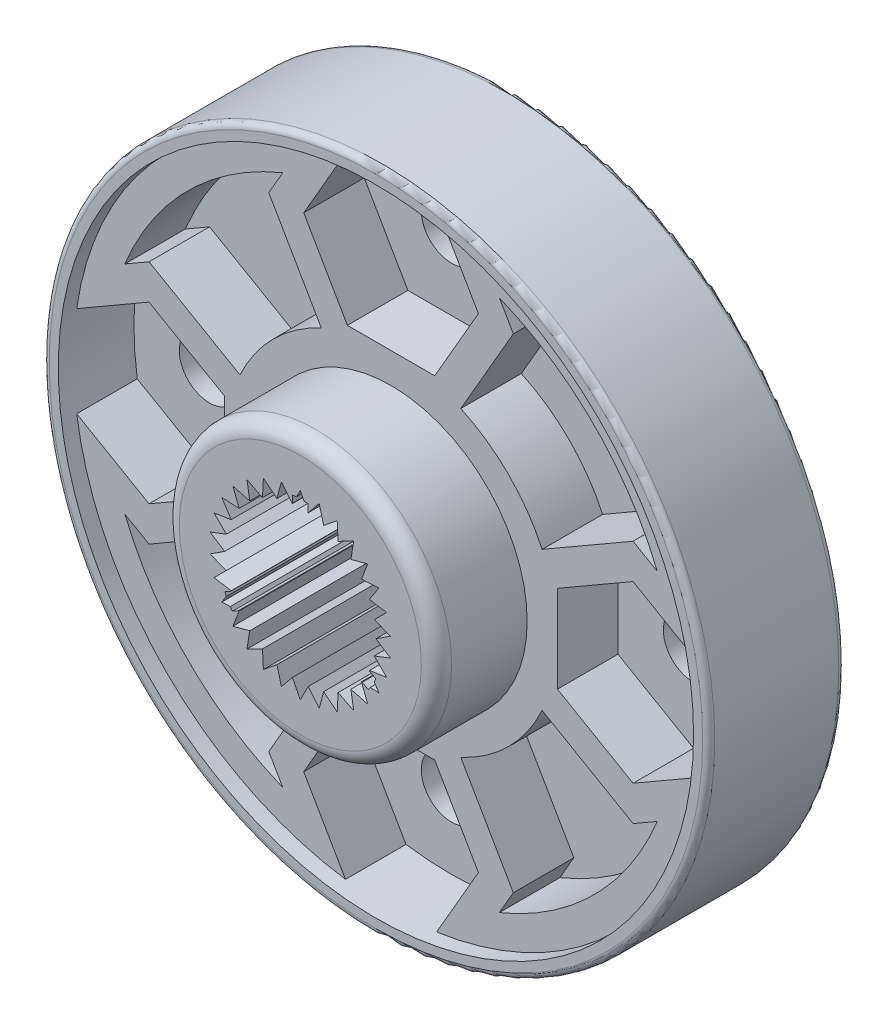
from build123d import *

# Parameters (mm, degrees)
SKETCH_1_R           = 11
EXTRUDE_1_DEPTH      = 4.5
SKETCH_2_R           = 4.5
EXTRUDE_2_DEPTH      = 2.5
SKETCH_3_R           = 3.75
EXTRUDE_3_DEPTH      = 0.5
SKETCH_4_R           = 2.75
CUT_EXTRUDE_1_DEPTH  = 2
CUT_EXTRUDE_2_DEPTH  = 5
SKETCH_6_R           = 1
CUT_EXTRUDE_3_DEPTH  = 8
SKETCH_7_R           = 0.75
CUT_EXTRUDE_4_DEPTH  = 0.2
SKETCH_8_R           = 1
CUT_EXTRUDE_5_DEPTH  = 0.2
EXTRUDE_4_DEPTH      = 0.1
EXTRUDE_5_DEPTH      = 0.1
EXTRUDE_6_DEPTH      = 0.1
SKETCH_12_R          = 10.5
SKETCH_12_R_2        = 4.5
CUT_EXTRUDE_7_DEPTH  = 0.5
SKETCH_13_R          = 1
CUT_EXTRUDE_9_DEPTH  = 2
FILLET_1_R           = 0.5
CUT_EXTRUDE_10_DEPTH = 6.5
FILLET_2_R           = 0.2


with BuildPart() as part:
    # 草图1 → 拉伸1 (new body)
    with BuildSketch(Plane.XY):
        Circle(SKETCH_1_R)
    extrude(amount=EXTRUDE_1_DEPTH)

    # 草图2 → 拉伸2 (add)
    with BuildSketch(Plane.XY.offset(4.5)):
        Circle(SKETCH_2_R)
    extrude(amount=EXTRUDE_2_DEPTH)

    # 草图3 → 拉伸3 (add)
    with BuildSketch(Plane(origin=(0, 0, 0), x_dir=(-1, 0, 0), z_dir=(0, 0, -1))):
        Circle(SKETCH_3_R)
    extrude(amount=EXTRUDE_3_DEPTH)

    # 草图4 → 切除-拉伸1 (cut)
    with BuildSketch(Plane(origin=(0, 0, -0.5), x_dir=(-1, 0, 0), z_dir=(0, 0, -1))):
        Circle(SKETCH_4_R)
    extrude(amount=-CUT_EXTRUDE_1_DEPTH, mode=Mode.SUBTRACT)

    # 草图5 → 切除-拉伸2 (cut)
    with BuildSketch(Plane.XY.offset(7)):
        Polygon((0, 3), (-0.261321158, 2.486304738), (-0.623735072, 2.934442802), (-0.772542486, 2.377641291), (-1.220209929, 2.740636373), (-1.25, 2.165063509), (-1.763355757, 2.427050983), (-1.672826516, 1.857862064), (-2.229434476, 2.007391819), (-2.022542486, 1.469463131), (-2.598076211, 1.5), (-2.283863644, 1.016841608), (-2.853169549, 0.927050983), (-2.445369002, 0.519779227), (-2.983565686, 0.31358539), (-2.5, 0), (-2.983565686, -0.31358539), (-2.445369002, -0.519779227), (-2.853169549, -0.927050983), (-2.283863644, -1.016841608), (-2.598076211, -1.5), (-2.022542486, -1.469463131), (-2.229434476, -2.007391819), (-1.672826516, -1.857862064), (-1.763355757, -2.427050983), (-1.25, -2.165063509), (-1.220209929, -2.740636373), (-0.772542486, -2.377641291), (-0.623735072, -2.934442802), (-0.261321158, -2.486304738), (0, -3), (0.261321158, -2.486304738), (0.623735072, -2.934442802), (0.772542486, -2.377641291), (1.220209929, -2.740636373), (1.25, -2.165063509), (1.763355757, -2.427050983), (1.672826516, -1.857862064), (2.229434476, -2.007391819), (2.022542486, -1.469463131), (2.598076211, -1.5), (2.283863644, -1.016841608), (2.853169549, -0.927050983), (2.445369002, -0.519779227), (2.983565686, -0.31358539), (2.5, 0), (2.983565686, 0.31358539), (2.445369002, 0.519779227), (2.853169549, 0.927050983), (2.283863644, 1.016841608), (2.598076211, 1.5), (2.022542486, 1.469463131), (2.229434476, 2.007391819), (1.672826516, 1.857862064), (1.763355757, 2.427050983), (1.25, 2.165063509), (1.220209929, 2.740636373), (0.772542486, 2.377641291), (0.623735072, 2.934442802), (0.261321158, 2.486304738), align=None)
    extrude(amount=-CUT_EXTRUDE_2_DEPTH, mode=Mode.SUBTRACT)

    # 草图6 → 切除-拉伸3 (cut, through all)
    with BuildSketch(Plane(origin=(0, 0, 0), x_dir=(-1, 0, 0), z_dir=(0, 0, -1))):
        with Locations((0, 8)):
            Circle(SKETCH_6_R)
        with Locations((8, 0)):
            Circle(SKETCH_6_R)
        with Locations((0, -8)):
            Circle(SKETCH_6_R)
        with Locations((-8, 0)):
            Circle(SKETCH_6_R)
    extrude(amount=-CUT_EXTRUDE_3_DEPTH, mode=Mode.SUBTRACT)

    # 草图7 → 切除-拉伸4 (cut)
    with BuildSketch(Plane(origin=(0, 0, 0), x_dir=(-1, 0, 0), z_dir=(0, 0, -1))):
        with Locations((0, 5.196152423)):
            Circle(SKETCH_7_R)
        with Locations((4.5, 2.598076211)):
            Circle(SKETCH_7_R)
        with Locations((4.5, -2.598076211)):
            Circle(SKETCH_7_R)
        with Locations((0, -5.196152423)):
            Circle(SKETCH_7_R)
        with Locations((-4.5, -2.598076211)):
            Circle(SKETCH_7_R)
        with Locations((-4.5, 2.598076211)):
            Circle(SKETCH_7_R)
    extrude(amount=-CUT_EXTRUDE_4_DEPTH, mode=Mode.SUBTRACT)

    # 草图8 → 切除-拉伸5 (cut)
    with BuildSketch(Plane(origin=(0, 0, 0), x_dir=(-1, 0, 0), z_dir=(0, 0, -1))):
        with Locations((0, 5.196152423)):
            Circle(SKETCH_8_R)
        with Locations((-4.5, -2.598076211)):
            Circle(SKETCH_8_R)
        with Locations((4.5, -2.598076211)):
            Circle(SKETCH_8_R)
    extrude(amount=-CUT_EXTRUDE_5_DEPTH, mode=Mode.SUBTRACT)

    # 草图9 → 拉伸4 (add)
    with BuildSketch(Plane(origin=(0, 0, 0.2), x_dir=(-1, 0, 0), z_dir=(0, 0, -1))):
        with BuildLine():
            Line((0.089651905, 6.056310688), (0.089651905, 4.73697475))
            add(Edge.make_bspline(
                [(0.089651905, 4.73697475), (0.090054867, 4.726061292), (0.090821432, 4.705300356), (0.099215446, 4.676319591), (0.112611431, 4.651356313), (0.13217496, 4.631390679), (0.156552186, 4.616383854), (0.185168592, 4.605627027), (0.217951485, 4.599206542), (0.241205917, 4.598399935), (0.253388884, 4.597977354)],
                knots=[0, 0, 0, 0, 3.2656e-05, 6.2122e-05, 8.9661e-05, 0.000116826, 0.000144913, 0.000174899, 0.000208095, 0.000244625, 0.000244625, 0.000244625, 0.000244625], degree=3))
            Line((0.253388884, 4.597977354), (0.339651905, 4.597977354))
            Line((0.339651905, 4.597977354), (0.339651905, 4.535477354))
            Line((0.339651905, 4.535477354), (-0.306181428, 4.535477354))
            Line((-0.306181428, 4.535477354), (-0.306181428, 4.597977354))
            Line((-0.306181428, 4.597977354), (-0.225777783, 4.597977354))
            add(Edge.make_bspline(
                [(-0.225777783, 4.597977354), (-0.211865389, 4.598406268), (-0.186051926, 4.599202087), (-0.1501756, 4.605109615), (-0.120288816, 4.615635163), (-0.096165753, 4.630911614), (-0.077851254, 4.650963182), (-0.06509053, 4.675284495), (-0.057494897, 4.703869515), (-0.056636456, 4.72422955), (-0.056181428, 4.735021625)],
                knots=[0, 0, 0, 0, 4.1729e-05, 7.7425e-05, 0.000108629, 0.000136168, 0.000162204, 0.000189145, 0.00021781, 0.000250141, 0.000250141, 0.000250141, 0.000250141], degree=3))
            Line((-0.056181428, 4.735021625), (-0.056181428, 5.770828917))
            add(Edge.make_bspline(
                [(-0.056181428, 5.770828917), (-0.056380806, 5.776286462), (-0.056766367, 5.78684037), (-0.061232198, 5.801922344), (-0.068381533, 5.815381019), (-0.078422418, 5.826992213), (-0.091012726, 5.836710591), (-0.106732564, 5.84355908), (-0.125232107, 5.847314594), (-0.138412095, 5.847748273), (-0.145374137, 5.847977354)],
                knots=[0, 0, 0, 0, 1.6328e-05, 3.1575e-05, 4.6722e-05, 6.1728e-05, 7.7288e-05, 9.4045e-05, 0.000112688, 0.000133562, 0.000133562, 0.000133562, 0.000133562], degree=3))
            Line((-0.145374137, 5.847977354), (-0.306181428, 5.847977354))
            Line((-0.306181428, 5.847977354), (-0.306181428, 5.910477354))
            Line((-0.306181428, 5.910477354), (-0.225126741, 5.910477354))
            add(Edge.make_bspline(
                [(-0.225126741, 5.910477354), (-0.207956505, 5.910865388), (-0.175202241, 5.911605607), (-0.128556059, 5.918495829), (-0.086854939, 5.929613877), (-0.049979918, 5.94579303), (-0.017577184, 5.9665729), (0.010725271, 5.99188936), (0.03495573, 6.02192616), (0.047249188, 6.044697076), (0.053519092, 6.056310688)],
                knots=[0, 0, 0, 0, 5.1483e-05, 9.8209e-05, 0.000141092, 0.000180589, 0.000218513, 0.000256089, 0.000294065, 0.000333594, 0.000333594, 0.000333594, 0.000333594], degree=3))
            Line((0.053519092, 6.056310688), (0.089651905, 6.056310688))
        make_face()
    extrude(amount=EXTRUDE_4_DEPTH)

    # 草图10 → 拉伸5 (add)
    with BuildSketch(Plane(origin=(0, 0, 0.2), x_dir=(-1, 0, 0), z_dir=(0, 0, -1))):
        with BuildLine():
            add(Edge.make_bspline(
                [(-4.923502604, -2.534274128), (-4.934438682, -2.54142001), (-4.955623116, -2.555262402), (-4.985188438, -2.577541336), (-5.011476174, -2.600438324), (-5.034386196, -2.624102537), (-5.054551495, -2.647963004), (-5.071504649, -2.672526123), (-5.084963819, -2.697944466), (-5.095468831, -2.72364453), (-5.102826259, -2.74993959), (-5.106408787, -2.776779833), (-5.10631326, -2.804013259), (-5.102981037, -2.831636465), (-5.096393948, -2.859672691), (-5.086556945, -2.888172234), (-5.073068652, -2.917044907), (-5.061810664, -2.935740273), (-5.055989583, -2.945406941)],
                knots=[0, 0, 0, 0, 3.9183e-05, 7.5902e-05, 0.000110965, 0.000143653, 0.00017462, 0.000204597, 0.000232994, 0.000260739, 0.000287748, 0.00031468, 0.000341698, 0.000369235, 0.000397977, 0.000427933, 0.000459536, 0.000493371, 0.000493371, 0.000493371, 0.000493371], degree=3))
            add(Edge.make_bspline(
                [(-5.055989583, -2.945406941), (-5.046458284, -2.959230981), (-5.027890491, -2.986161405), (-4.992903828, -3.019703109), (-4.954205817, -3.046703542), (-4.918424437, -3.062235248), (-4.888975583, -3.071119168), (-4.866897586, -3.075034354), (-4.845174123, -3.076277145), (-4.823957293, -3.075480516), (-4.803145293, -3.071652662), (-4.782649248, -3.065941006), (-4.76252748, -3.057370768), (-4.749918009, -3.04983479), (-4.743489583, -3.045992878)],
                knots=[0, 0, 0, 0, 5.0261e-05, 9.7913e-05, 0.000144503, 0.000191139, 0.000214212, 0.00023669, 0.000258213, 0.000279395, 0.000300213, 0.000321541, 0.000343127, 0.000365576, 0.000365576, 0.000365576, 0.000365576], degree=3))
            add(Edge.make_bspline(
                [(-4.743489583, -3.045992878), (-4.736283626, -3.040984911), (-4.722267198, -3.031243831), (-4.704288218, -3.013651985), (-4.691137931, -2.993321697), (-4.682143835, -2.971757183), (-4.67484291, -2.950513489), (-4.663744304, -2.932639535), (-4.651470767, -2.91721807), (-4.641145958, -2.909929378), (-4.636067708, -2.906344441)],
                knots=[0, 0, 0, 0, 2.6303e-05, 5.1162e-05, 7.4907e-05, 9.8374e-05, 0.000121163, 0.000142042, 0.000161215, 0.000179772, 0.000179772, 0.000179772, 0.000179772], degree=3))
            add(Edge.make_bspline(
                [(-4.636067708, -2.906344441), (-4.629880584, -2.90266612), (-4.618227256, -2.895738075), (-4.600153119, -2.889044397), (-4.583005407, -2.886252397), (-4.566665212, -2.887048246), (-4.551336831, -2.89224464), (-4.536852904, -2.900852239), (-4.524184985, -2.914140072), (-4.516888268, -2.924576111), (-4.513020833, -2.930107461)],
                knots=[0, 0, 0, 0, 2.1563e-05, 4.0614e-05, 5.7418e-05, 7.3399e-05, 8.9149e-05, 0.000105506, 0.00012346, 0.000143708, 0.000143708, 0.000143708, 0.000143708], degree=3))
            add(Edge.make_bspline(
                [(-4.513020833, -2.930107461), (-4.508913691, -2.937125984), (-4.501015104, -2.950623547), (-4.494520421, -2.972560199), (-4.492321165, -2.994269974), (-4.495275481, -3.016007298), (-4.504119473, -3.037348703), (-4.519145779, -3.058095292), (-4.54066524, -3.077742758), (-4.557878585, -3.089306101), (-4.567057292, -3.095472045)],
                knots=[0, 0, 0, 0, 2.4318e-05, 4.6768e-05, 6.8016e-05, 8.9377e-05, 0.000111864, 0.000136612, 0.000165629, 0.000198778, 0.000198778, 0.000198778, 0.000198778], degree=3))
            add(Edge.make_bspline(
                [(-4.567057292, -3.095472045), (-4.580036634, -3.103241135), (-4.605362781, -3.118400697), (-4.644955142, -3.135879651), (-4.684141672, -3.148946663), (-4.723342795, -3.156367591), (-4.762220025, -3.159444899), (-4.801096167, -3.157551866), (-4.839627282, -3.150155326), (-4.877503904, -3.138401383), (-4.913913093, -3.123052842), (-4.948595748, -3.105553198), (-4.980723318, -3.085547475), (-5.010989645, -3.064104083), (-5.038767581, -3.040228739), (-5.064122499, -3.014091835), (-5.087462554, -2.986099225), (-5.1009747, -2.965932019), (-5.107747396, -2.955823607)],
                knots=[0, 0, 0, 0, 4.5342e-05, 8.8475e-05, 0.000129548, 0.000169002, 0.00020785, 0.000246311, 0.000285384, 0.000325232, 0.000365071, 0.000403796, 0.000441649, 0.000478506, 0.000514979, 0.00055135, 0.000587652, 0.000624134, 0.000624134, 0.000624134, 0.000624134], degree=3))
            add(Edge.make_bspline(
                [(-5.107747396, -2.955823607), (-5.116474892, -2.941536596), (-5.133379472, -2.913863603), (-5.153637862, -2.871266437), (-5.170439256, -2.830256823), (-5.181709635, -2.789907598), (-5.189245184, -2.750829479), (-5.1914856, -2.712658245), (-5.189321381, -2.675687239), (-5.18233837, -2.639987105), (-5.17144576, -2.60586942), (-5.157747844, -2.573170822), (-5.141193472, -2.542058477), (-5.121102771, -2.512894253), (-5.097962867, -2.485657292), (-5.07198717, -2.459998938), (-5.042922393, -2.436078695), (-5.021619732, -2.421997903), (-5.010742187, -2.414807982)],
                knots=[0, 0, 0, 0, 5.019e-05, 9.7216e-05, 0.000141342, 0.000182971, 0.000222685, 0.000260514, 0.000297368, 0.000333502, 0.00036933, 0.000404637, 0.000439736, 0.000474859, 0.000510662, 0.0005468, 0.000584271, 0.000623367, 0.000623367, 0.000623367, 0.000623367], degree=3))
            add(Edge.make_bspline(
                [(-5.010742187, -2.414807982), (-4.995523968, -2.40586697), (-4.964773778, -2.387800609), (-4.914775923, -2.367321955), (-4.861777201, -2.351557983), (-4.805762047, -2.340757328), (-4.746507714, -2.335866148), (-4.684417769, -2.337623814), (-4.619683572, -2.346223471), (-4.576311745, -2.356480296), (-4.554036458, -2.361748086)],
                knots=[0, 0, 0, 0, 5.2896e-05, 0.000106882, 0.000161571, 0.000218582, 0.000277703, 0.000339573, 0.00040458, 0.000473218, 0.000473218, 0.000473218, 0.000473218], degree=3))
            add(Edge.make_bspline(
                [(-4.554036458, -2.361748086), (-4.526047464, -2.367851881), (-4.471609687, -2.379723584), (-4.392063103, -2.396596104), (-4.316972392, -2.412541141), (-4.246068169, -2.42574144), (-4.179921773, -2.438929245), (-4.117986253, -2.449442248), (-4.06048495, -2.458935808), (-4.007423022, -2.467084975), (-3.958816058, -2.473981797), (-3.914756948, -2.479526143), (-3.875134531, -2.483754492), (-3.84008646, -2.487043942), (-3.809480851, -2.489354396), (-3.783334668, -2.49076807), (-3.761683458, -2.491065035), (-3.748802198, -2.489873701), (-3.743164062, -2.489352253)],
                knots=[0, 0, 0, 0, 8.594e-05, 0.000167151, 0.000243952, 0.000316221, 0.00038351, 0.000446285, 0.00050467, 0.000558351, 0.000607333, 0.000651948, 0.000691563, 0.000726869, 0.000757553, 0.000783627, 0.000805437, 0.000822414, 0.000822414, 0.000822414, 0.000822414], degree=3))
            Line((-3.743164062, -2.489352253), (-4.015625, -2.056409545))
            add(Edge.make_bspline(
                [(-4.015625, -2.056409545), (-4.022878312, -2.046136926), (-4.037100032, -2.025995188), (-4.066152514, -2.00273789), (-4.099872125, -1.986475093), (-4.138263413, -1.977560621), (-4.180981408, -1.975621502), (-4.227535668, -1.98259356), (-4.278329551, -1.996381336), (-4.312338361, -2.010924097), (-4.330403646, -2.018649128)],
                knots=[0, 0, 0, 0, 3.7572e-05, 7.3668e-05, 0.000110211, 0.000149055, 0.000191093, 0.000237729, 0.00028969, 0.000348566, 0.000348566, 0.000348566, 0.000348566], degree=3))
            Line((-4.330403646, -2.018649128), (-4.358072917, -1.974703816))
            Line((-4.358072917, -1.974703816), (-4.017578125, -1.822034545))
            Line((-4.017578125, -1.822034545), (-3.586588542, -2.506930378))
            Line((-3.586588542, -2.506930378), (-3.676757812, -2.563896524))
            add(Edge.make_bspline(
                [(-3.676757812, -2.563896524), (-3.693356187, -2.564599484), (-3.729365939, -2.56612454), (-3.787829332, -2.564924397), (-3.854665009, -2.560297478), (-3.91578789, -2.555054496), (-3.968767835, -2.54852254), (-4.012006257, -2.543140007), (-4.05734407, -2.536227122), (-4.105045624, -2.528264043), (-4.155004111, -2.519950018), (-4.20732792, -2.51049628), (-4.261739685, -2.499655684), (-4.298829638, -2.492180527), (-4.317708333, -2.488375691)],
                knots=[0, 0, 0, 0, 4.9831e-05, 0.000108108, 0.000175298, 0.000250804, 0.000292109, 0.000335433, 0.000381515, 0.000429679, 0.000480519, 0.000533451, 0.000589183, 0.000646959, 0.000646959, 0.000646959, 0.000646959], degree=3))
            add(Edge.make_bspline(
                [(-4.317708333, -2.488375691), (-4.334613308, -2.484998444), (-4.367788698, -2.478370722), (-4.417007813, -2.470688845), (-4.464330988, -2.464476802), (-4.509919295, -2.45986688), (-4.553667756, -2.456802468), (-4.595806713, -2.455936019), (-4.636114179, -2.456373422), (-4.686470387, -2.459999077), (-4.745472047, -2.467204844), (-4.811147228, -2.48297043), (-4.870847598, -2.504161793), (-4.906280328, -2.524425056), (-4.923502604, -2.534274128)],
                knots=[0, 0, 0, 0, 5.1712e-05, 0.000101482, 0.000149409, 0.000194885, 0.000238928, 0.000280932, 0.000321302, 0.000359801, 0.000432358, 0.000499311, 0.000562137, 0.000621555, 0.000621555, 0.000621555, 0.000621555], degree=3))
        make_face()
    extrude(amount=EXTRUDE_5_DEPTH)

    # 草图11 → 拉伸6 (add)
    with BuildSketch(Plane(origin=(0, 0, 0.2), x_dir=(-1, 0, 0), z_dir=(0, 0, -1))):
        with BuildLine():
            add(Edge.make_bspline(
                [(4.636393229, -2.007255899), (4.648080062, -2.000262717), (4.671074872, -1.986503053), (4.707788762, -1.970590653), (4.745126004, -1.95815138), (4.783624565, -1.949541039), (4.823010156, -1.945194267), (4.86345118, -1.943973623), (4.904718515, -1.947566033), (4.946711452, -1.954221167), (4.988393736, -1.965070344), (5.02886982, -1.98080756), (5.067255504, -2.001517072), (5.10415678, -2.026434302), (5.138978261, -2.056339085), (5.172248687, -2.090619177), (5.203661577, -2.129582309), (5.222453408, -2.158025158), (5.232096354, -2.172620482)],
                knots=[0, 0, 0, 0, 4.082e-05, 8.0317e-05, 0.000119743, 0.000158758, 0.000198408, 0.000238459, 0.000279928, 0.000322473, 0.0003659, 0.00040888, 0.000452423, 0.000496482, 0.000542206, 0.000589858, 0.000639629, 0.000692087, 0.000692087, 0.000692087, 0.000692087], degree=3))
            add(Edge.make_bspline(
                [(5.232096354, -2.172620482), (5.23871605, -2.183461815), (5.25179083, -2.204874889), (5.267367619, -2.238604418), (5.281055729, -2.272114464), (5.291266585, -2.306224972), (5.297836704, -2.340723517), (5.302384415, -2.375396927), (5.303171755, -2.410382043), (5.30133462, -2.445232659), (5.296446535, -2.478848653), (5.289419611, -2.510652378), (5.279359707, -2.53975784), (5.266874515, -2.566520749), (5.252051509, -2.590789505), (5.233958438, -2.612112368), (5.214048768, -2.631668121), (5.1985329, -2.642033812), (5.190755208, -2.647229857)],
                knots=[0, 0, 0, 0, 3.8076e-05, 7.5206e-05, 0.000111293, 0.000146619, 0.000181795, 0.000216559, 0.000251403, 0.000286613, 0.00032114, 0.0003532, 0.000384186, 0.000413311, 0.000441674, 0.000469182, 0.000497042, 0.000525045, 0.000525045, 0.000525045, 0.000525045], degree=3))
            add(Edge.make_bspline(
                [(5.190755208, -2.647229857), (5.183407364, -2.651447664), (5.168951543, -2.659745591), (5.144951356, -2.666734899), (5.120171101, -2.669975071), (5.095305639, -2.667680243), (5.072285326, -2.662460312), (5.052351812, -2.654628084), (5.03617435, -2.644169725), (5.028858547, -2.634541389), (5.025390625, -2.629977253)],
                knots=[0, 0, 0, 0, 2.5334e-05, 4.9841e-05, 7.4431e-05, 9.9896e-05, 0.000124295, 0.000145029, 0.00016399, 0.00018108, 0.00018108, 0.00018108, 0.00018108], degree=3))
            add(Edge.make_bspline(
                [(5.025390625, -2.629977253), (5.021520719, -2.622979301), (5.014153461, -2.609657088), (5.009730727, -2.587713607), (5.011687217, -2.566154618), (5.020293535, -2.546409406), (5.031600421, -2.528881834), (5.043055586, -2.513661588), (5.054536008, -2.501456877), (5.06284264, -2.495429469), (5.066731771, -2.492607461)],
                knots=[0, 0, 0, 0, 2.3876e-05, 4.5454e-05, 6.6055e-05, 8.7816e-05, 0.000109313, 0.000128585, 0.000144929, 0.000159318, 0.000159318, 0.000159318, 0.000159318], degree=3))
            add(Edge.make_bspline(
                [(5.066731771, -2.492607461), (5.072952041, -2.488990062), (5.084979844, -2.481995292), (5.103766427, -2.474148628), (5.122224324, -2.468655769), (5.145645598, -2.466383413), (5.172536943, -2.464035836), (5.191027489, -2.454624591), (5.199544271, -2.450289753)],
                knots=[0, 0, 0, 0, 2.1563e-05, 4.1695e-05, 6.0967e-05, 7.9015e-05, 0.000112303, 0.000140728, 0.000140728, 0.000140728, 0.000140728], degree=3))
            add(Edge.make_bspline(
                [(5.199544271, -2.450289753), (5.20663032, -2.444970251), (5.220905839, -2.43425361), (5.234278826, -2.409387071), (5.241310533, -2.379773024), (5.241609527, -2.345751659), (5.237225882, -2.309609133), (5.227429213, -2.273405741), (5.213716493, -2.237941806), (5.200631642, -2.215966857), (5.194010417, -2.204847045)],
                knots=[0, 0, 0, 0, 2.6305e-05, 5.2994e-05, 8.2521e-05, 0.00011704, 0.000154428, 0.000191459, 0.000229299, 0.000268062, 0.000268062, 0.000268062, 0.000268062], degree=3))
            add(Edge.make_bspline(
                [(5.194010417, -2.204847045), (5.186886405, -2.194220127), (5.173014562, -2.173527441), (5.150449305, -2.145146028), (5.126284917, -2.120798567), (5.101363674, -2.09967484), (5.07459611, -2.082768526), (5.047084213, -2.06873923), (5.01798643, -2.059538012), (4.988146005, -2.053007448), (4.956834879, -2.050979435), (4.924287495, -2.05218285), (4.890417794, -2.057717453), (4.855108794, -2.06654508), (4.818398164, -2.079279509), (4.780437498, -2.096188768), (4.74110043, -2.116664188), (4.714971843, -2.132534936), (4.701497396, -2.140719441)],
                knots=[0, 0, 0, 0, 3.8376e-05, 7.4725e-05, 0.000108562, 0.000141154, 0.000172487, 0.00020335, 0.000233511, 0.000263773, 0.000294781, 0.000327359, 0.00036129, 0.000397528, 0.000436441, 0.00047769, 0.000522097, 0.000569383, 0.000569383, 0.000569383, 0.000569383], degree=3))
            add(Edge.make_bspline(
                [(4.701497396, -2.140719441), (4.69064128, -2.147827362), (4.66937464, -2.161751459), (4.640012788, -2.18498432), (4.613622647, -2.209417363), (4.59006124, -2.234759705), (4.569561385, -2.261392494), (4.552412669, -2.289414636), (4.537947819, -2.318433616), (4.526659934, -2.348661877), (4.519097203, -2.380665192), (4.517471803, -2.41496639), (4.520544228, -2.451373204), (4.528567969, -2.489884389), (4.541446016, -2.53055242), (4.559692518, -2.573168827), (4.582456919, -2.618300592), (4.600791611, -2.64822726), (4.610351563, -2.66383142)],
                knots=[0, 0, 0, 0, 3.8913e-05, 7.6229e-05, 0.000112163, 0.000146717, 0.000179922, 0.000212806, 0.000245125, 0.000277052, 0.00030943, 0.00034334, 0.000379592, 0.00041879, 0.000461103, 0.000507353, 0.000557723, 0.000612601, 0.000612601, 0.000612601, 0.000612601], degree=3))
            Line((4.610351563, -2.66383142), (4.568684896, -2.689873086))
            add(Edge.make_bspline(
                [(4.568684896, -2.689873086), (4.560966213, -2.677903384), (4.546043385, -2.654761892), (4.520986125, -2.623360559), (4.495383871, -2.595633115), (4.469056859, -2.571679823), (4.441796702, -2.551842558), (4.413539628, -2.5361554), (4.384598873, -2.523858015), (4.354620464, -2.516113295), (4.324251222, -2.511955074), (4.293460666, -2.5108404), (4.262271384, -2.513667703), (4.230504282, -2.519481097), (4.198313324, -2.5291077), (4.165587643, -2.541815895), (4.13260136, -2.558275106), (4.11102539, -2.571233194), (4.099934896, -2.57789392)],
                knots=[0, 0, 0, 0, 4.2704e-05, 8.2561e-05, 0.000120336, 0.000155831, 0.00018917, 0.00022123, 0.000252605, 0.00028324, 0.000313808, 0.000344422, 0.000375456, 0.000407571, 0.000441152, 0.000476092, 0.000512778, 0.00055158, 0.00055158, 0.00055158, 0.00055158], degree=3))
            add(Edge.make_bspline(
                [(4.099934896, -2.57789392), (4.082395375, -2.589871275), (4.048099197, -2.613291383), (4.004225703, -2.656288595), (3.967716823, -2.703680429), (3.944308572, -2.747088355), (3.930307719, -2.783442205), (3.924577261, -2.811484667), (3.922279591, -2.839678621), (3.923417217, -2.868301445), (3.929287081, -2.897105506), (3.9385124, -2.926356111), (3.951455003, -2.956035767), (3.962884146, -2.975040856), (3.96875, -2.984794961)],
                knots=[0, 0, 0, 0, 6.3613e-05, 0.000124387, 0.000183374, 0.000242504, 0.000271651, 0.000299933, 0.000328021, 0.000356371, 0.000385546, 0.000415918, 0.000448276, 0.000482393, 0.000482393, 0.000482393, 0.000482393], degree=3))
            add(Edge.make_bspline(
                [(3.96875, -2.984794961), (3.974719352, -2.993536933), (3.986933499, -3.011424259), (4.009911837, -3.035683326), (4.0360682, -3.059341539), (4.065115794, -3.080858162), (4.096212134, -3.097981749), (4.129214414, -3.104647701), (4.162195891, -3.10078822), (4.181457034, -3.090414075), (4.19140625, -3.085055378)],
                knots=[0, 0, 0, 0, 3.1711e-05, 6.4886e-05, 9.9921e-05, 0.000137424, 0.000173237, 0.000205413, 0.000236906, 0.000270554, 0.000270554, 0.000270554, 0.000270554], degree=3))
            add(Edge.make_bspline(
                [(4.19140625, -3.085055378), (4.200507332, -3.079116456), (4.216976142, -3.068369714), (4.237738676, -3.052202457), (4.251612942, -3.037167269), (4.258745952, -3.023114627), (4.261612654, -3.010376641), (4.268455272, -3.000164389), (4.276514971, -2.990707404), (4.283503894, -2.985948121), (4.287109375, -2.983492878)],
                knots=[0, 0, 0, 0, 3.2593e-05, 5.8978e-05, 7.8821e-05, 9.3379e-05, 0.000105732, 0.000117568, 0.000129786, 0.000142807, 0.000142807, 0.000142807, 0.000142807], degree=3))
            add(Edge.make_bspline(
                [(4.287109375, -2.983492878), (4.293328327, -2.979876334), (4.305144115, -2.973005029), (4.323263783, -2.965384585), (4.340556558, -2.960599386), (4.357217831, -2.959182576), (4.373411863, -2.96107953), (4.38811775, -2.968888746), (4.401572377, -2.980731383), (4.408644291, -2.99100628), (4.412434896, -2.996513711)],
                knots=[0, 0, 0, 0, 2.1563e-05, 4.0969e-05, 5.8814e-05, 7.5142e-05, 9.0932e-05, 0.000106945, 0.000124247, 0.000144234, 0.000144234, 0.000144234, 0.000144234], degree=3))
            add(Edge.make_bspline(
                [(4.412434896, -2.996513711), (4.415132239, -3.001527402), (4.420506156, -3.01151618), (4.425053086, -3.028365658), (4.426624473, -3.046422902), (4.425104947, -3.065692095), (4.419015698, -3.08610679), (4.404859609, -3.105481635), (4.385153943, -3.124850252), (4.368610739, -3.135798984), (4.359700521, -3.141696003)],
                knots=[0, 0, 0, 0, 1.7033e-05, 3.3935e-05, 5.1913e-05, 7.1187e-05, 9.1674e-05, 0.000114878, 0.00014227, 0.000174246, 0.000174246, 0.000174246, 0.000174246], degree=3))
            add(Edge.make_bspline(
                [(4.359700521, -3.141696003), (4.350494148, -3.147147336), (4.332400127, -3.157861277), (4.303449822, -3.169559848), (4.27404123, -3.177492719), (4.24393879, -3.181358541), (4.213227061, -3.181726933), (4.181840112, -3.178100579), (4.149962844, -3.170294495), (4.117766189, -3.159421086), (4.086206908, -3.145064739), (4.055793672, -3.128489027), (4.027048296, -3.109408786), (3.999635892, -3.088422905), (3.974206977, -3.064630629), (3.949904519, -3.039052073), (3.927903363, -3.010516499), (3.914385718, -2.990404817), (3.907552083, -2.98023767)],
                knots=[0, 0, 0, 0, 3.206e-05, 6.301e-05, 9.3331e-05, 0.00012321, 0.00015381, 0.000185265, 0.000217716, 0.000252098, 0.000287067, 0.000321594, 0.000355902, 0.000390476, 0.00042503, 0.000460266, 0.000496211, 0.00053296, 0.00053296, 0.00053296, 0.00053296], degree=3))
            add(Edge.make_bspline(
                [(3.907552083, -2.98023767), (3.900281208, -2.967985194), (3.886044793, -2.943994776), (3.868799467, -2.906740582), (3.855374483, -2.869447486), (3.847276776, -2.831864544), (3.841913351, -2.794434768), (3.841754427, -2.756926473), (3.845774828, -2.719415807), (3.853573987, -2.682387124), (3.864562392, -2.646613277), (3.878052637, -2.612969533), (3.893074399, -2.581587643), (3.910957881, -2.553124535), (3.930404756, -2.52695946), (3.95203604, -2.503332693), (3.97585047, -2.482221018), (3.99345208, -2.470493562), (4.002278646, -2.46461267)],
                knots=[0, 0, 0, 0, 4.2718e-05, 8.3642e-05, 0.000122969, 0.000161349, 0.000198778, 0.000236214, 0.000273529, 0.00031177, 0.00034956, 0.000385647, 0.000420441, 0.000453774, 0.000486326, 0.00051812, 0.000549723, 0.00058151, 0.00058151, 0.00058151, 0.00058151], degree=3))
            add(Edge.make_bspline(
                [(4.002278646, -2.46461267), (4.021319553, -2.453653424), (4.058267272, -2.432387677), (4.116829519, -2.41024601), (4.17562695, -2.398271701), (4.224827924, -2.396442872), (4.263739406, -2.400422683), (4.293044533, -2.405814666), (4.321998171, -2.414911735), (4.351154331, -2.426221685), (4.380066561, -2.440774557), (4.409246635, -2.457571584), (4.43782085, -2.477983754), (4.456352497, -2.493048768), (4.465820313, -2.500745482)],
                knots=[0, 0, 0, 0, 6.5833e-05, 0.000127744, 0.00018686, 0.000245161, 0.000274604, 0.000304099, 0.000334374, 0.000365505, 0.000397824, 0.000431378, 0.000466419, 0.000503023, 0.000503023, 0.000503023, 0.000503023], degree=3))
            add(Edge.make_bspline(
                [(4.465820313, -2.500745482), (4.462581307, -2.484721232), (4.456306999, -2.453680512), (4.450474115, -2.408002291), (4.447698608, -2.364826242), (4.448363889, -2.324013133), (4.451850336, -2.285692136), (4.458161274, -2.249717897), (4.468403704, -2.216398762), (4.485562066, -2.175761742), (4.512469947, -2.130397799), (4.548557144, -2.081492058), (4.589597794, -2.039756666), (4.62094913, -2.017982267), (4.636393229, -2.007255899)],
                knots=[0, 0, 0, 0, 4.9032e-05, 9.498e-05, 0.000138027, 0.000178723, 0.000217301, 0.000253375, 0.000288077, 0.000321631, 0.000385507, 0.000445728, 0.000503733, 0.000560049, 0.000560049, 0.000560049, 0.000560049], degree=3))
        make_face()
    extrude(amount=EXTRUDE_6_DEPTH)

    # 草图12 → 切除-拉伸7 (cut)
    with BuildSketch(Plane.XY.offset(4.5)):
        Circle(SKETCH_12_R)
        Circle(SKETCH_12_R_2, mode=Mode.SUBTRACT)
    extrude(amount=-CUT_EXTRUDE_7_DEPTH, mode=Mode.SUBTRACT)

    # 草图13 → 切除-拉伸9 (cut)
    with BuildSketch(Plane.XY.offset(4)):
        with BuildLine():
            Line((1.443375673, 5.5), (2.886751346, 8))
            Line((2.886751346, 8), (1.506059499, 10.391428429))
            ThreePointArc((1.506059499, 10.391428429), (0.75498394, 10.472821933), (0, 10.5))
            ThreePointArc((0, 10.5), (-0.75498394, 10.472821933), (-1.506059499, 10.391428429))
            Line((-1.506059499, 10.391428429), (-2.886751346, 8))
            Line((-2.886751346, 8), (-1.443375673, 5.5))
            Line((-1.443375673, 5.5), (1.443375673, 5.5))
        make_face()
        with Locations((0, 8)):
            Circle(SKETCH_13_R, mode=Mode.SUBTRACT)
        with BuildLine():
            ThreePointArc((10.5, 0), (10.472821933, 0.75498394), (10.391428429, 1.506059499))
            Line((10.391428429, 1.506059499), (8, 2.886751346))
            Line((8, 2.886751346), (5.5, 1.443375673))
            Line((5.5, 1.443375673), (5.5, -1.443375673))
            Line((5.5, -1.443375673), (8, -2.886751346))
            Line((8, -2.886751346), (10.391428429, -1.506059499))
            ThreePointArc((10.391428429, -1.506059499), (10.472821933, -0.75498394), (10.5, 0))
        make_face()
        with Locations((8, 0)):
            Circle(SKETCH_13_R, mode=Mode.SUBTRACT)
        with BuildLine():
            ThreePointArc((1e-08, -10.5), (0.754983946, -10.472821933), (1.506059499, -10.391428429))
            Line((1.506059499, -10.391428429), (2.886751346, -8))
            Line((2.886751346, -8), (1.443375673, -5.5))
            Line((1.443375673, -5.5), (-1.443375673, -5.5))
            Line((-1.443375673, -5.5), (-2.886751346, -8))
            Line((-2.886751346, -8), (-1.506059499, -10.391428429))
            ThreePointArc((-1.506059499, -10.391428429), (-0.754983935, -10.472821934), (1e-08, -10.5))
        make_face()
        with Locations((0, -8)):
            Circle(SKETCH_13_R, mode=Mode.SUBTRACT)
        with BuildLine():
            Line((-8, 2.886751346), (-10.391428429, 1.506059499))
            ThreePointArc((-10.391428429, 1.506059499), (-10.472821932, 0.754983962), (-10.5, 4.4e-08))
            ThreePointArc((-10.5, 4.4e-08), (-10.472821935, -0.754983918), (-10.391428429, -1.506059499))
            Line((-10.391428429, -1.506059499), (-8, -2.886751346))
            Line((-8, -2.886751346), (-5.5, -1.443375673))
            Line((-5.5, -1.443375673), (-5.5, 1.443375673))
            Line((-5.5, 1.443375673), (-8, 2.886751346))
        make_face()
        with Locations((-8, 0)):
            Circle(SKETCH_13_R, mode=Mode.SUBTRACT)
        with BuildLine():
            ThreePointArc((-4.99341649, 2.305600086), (-3.889087297, 3.889087297), (-2.305600086, 4.99341649))
            Line((-2.305600086, 4.99341649), (-4.041451884, 8))
            Line((-4.041451884, 8), (-3.579714581, 8.799752469))
            ThreePointArc((-3.579714581, 8.799752469), (-6.717514421, 6.717514421), (-8.799752469, 3.579714581))
            Line((-8.799752469, 3.579714581), (-8, 4.041451884))
            Line((-8, 4.041451884), (-4.99341649, 2.305600086))
        make_face()
        with BuildLine():
            Line((3.579714581, 8.799752469), (4.041451884, 8))
            Line((4.041451884, 8), (2.305600086, 4.99341649))
            ThreePointArc((2.305600086, 4.99341649), (3.889087297, 3.889087297), (4.99341649, 2.305600086))
            Line((4.99341649, 2.305600086), (8, 4.041451884))
            Line((8, 4.041451884), (8.799752469, 3.579714581))
            ThreePointArc((8.799752469, 3.579714581), (6.717514421, 6.717514421), (3.579714581, 8.799752469))
        make_face()
        with BuildLine():
            Line((8, -4.041451884), (4.99341649, -2.305600086))
            ThreePointArc((4.99341649, -2.305600086), (3.889087297, -3.889087297), (2.305600086, -4.99341649))
            Line((2.305600086, -4.99341649), (4.041451884, -8))
            Line((4.041451884, -8), (3.579714581, -8.799752469))
            ThreePointArc((3.579714581, -8.799752469), (6.717514421, -6.717514421), (8.799752469, -3.579714581))
            Line((8.799752469, -3.579714581), (8, -4.041451884))
        make_face()
        with BuildLine():
            Line((-4.041451884, -8), (-2.305600086, -4.99341649))
            ThreePointArc((-2.305600086, -4.99341649), (-3.889087297, -3.889087297), (-4.99341649, -2.305600086))
            Line((-4.99341649, -2.305600086), (-8, -4.041451884))
            Line((-8, -4.041451884), (-8.799752469, -3.579714581))
            ThreePointArc((-8.799752469, -3.579714581), (-6.717514421, -6.717514421), (-3.579714581, -8.799752469))
            Line((-3.579714581, -8.799752469), (-4.041451884, -8))
        make_face()
    extrude(amount=-CUT_EXTRUDE_9_DEPTH, mode=Mode.SUBTRACT)

    # 圆角1
    fillet_1_edges = [part.edges().sort_by_distance(p)[0] for p in [
        (-4.5, 0, 7),
    ]]
    fillet(fillet_1_edges, radius=FILLET_1_R)

    # 草图14 → 切除-拉伸10 (cut, through all)
    with BuildSketch(Plane(origin=(0, 0, 1.5), x_dir=(-1, 0, 0), z_dir=(0, 0, -1))):
        with BuildLine():
            Line((-0.25, 2.738612788), (-0.25, 1.479019946))
            ThreePointArc((-0.25, 1.479019946), (-1.299038106, 0.75), (-1.405868846, -0.523003622))
            Line((-1.405868846, -0.523003622), (-2.496708245, -1.152800043))
            ThreePointArc((-2.496708245, -1.152800043), (-2.38156986, -1.375), (-2.246708245, -1.585812745))
            Line((-2.246708245, -1.585812745), (-1.155868846, -0.956016324))
            ThreePointArc((-1.155868846, -0.956016324), (0, -1.5), (1.155868846, -0.956016324))
            Line((1.155868846, -0.956016324), (2.246708245, -1.585812745))
            ThreePointArc((2.246708245, -1.585812745), (2.38156986, -1.375), (2.496708245, -1.152800043))
            Line((2.496708245, -1.152800043), (1.405868846, -0.523003622))
            ThreePointArc((1.405868846, -0.523003622), (1.299038106, 0.75), (0.25, 1.479019946))
            Line((0.25, 1.479019946), (0.25, 2.738612788))
            ThreePointArc((0.25, 2.738612788), (0, 2.75), (-0.25, 2.738612788))
        make_face()
    extrude(amount=-CUT_EXTRUDE_10_DEPTH, mode=Mode.SUBTRACT)

    # 圆角2
    fillet_2_edges = [part.edges().sort_by_distance(p)[0] for p in [
        (-11, 0, 0),
        (-11, 0, 4.5),
    ]]
    fillet(fillet_2_edges, radius=FILLET_2_R)


solid = part.part
